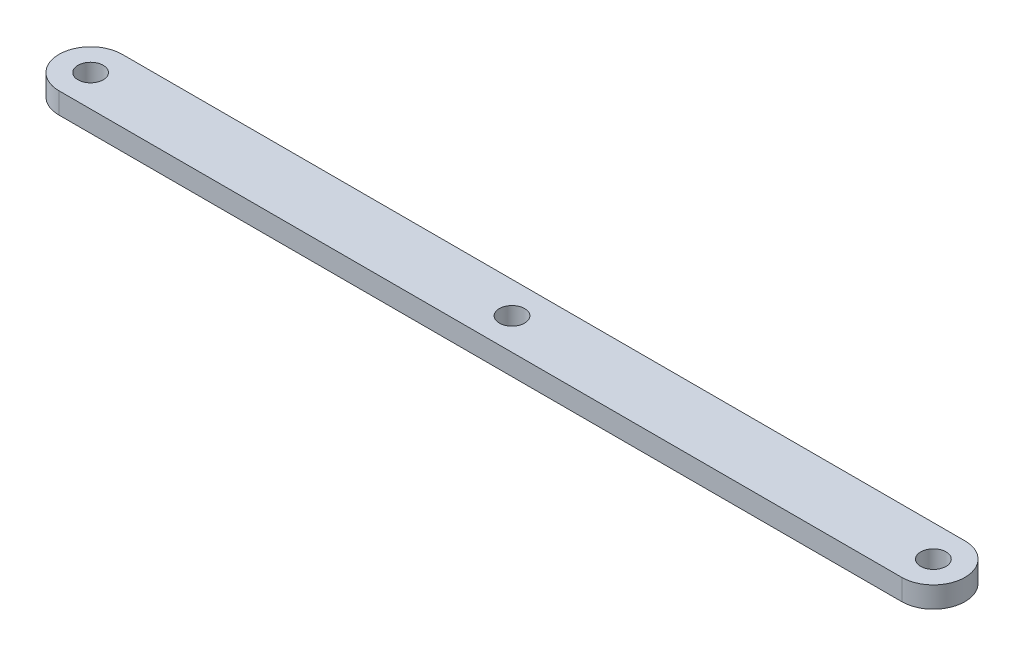
from build123d import *

# Parameters (mm, degrees)
SKETCH1_R           = 3
BOSS_EXTRUDE1_DEPTH = 5


with BuildPart() as part:
    # Sketch1 → Boss-Extrude1 (new body)
    with BuildSketch(Plane(origin=(0, 0, 0), x_dir=(1, 0, 0), z_dir=(0, 1, 0))):
        with BuildLine():
            Line((0, 7.5), (200, 7.5))
            ThreePointArc((200, 7.5), (207.5, 0), (200, -7.5))
            Line((200, -7.5), (0, -7.5))
            ThreePointArc((0, -7.5), (-7.5, 0), (0, 7.5))
        make_face()
        with Locations((200, 0)):
            Circle(SKETCH1_R, mode=Mode.SUBTRACT)
        Circle(SKETCH1_R, mode=Mode.SUBTRACT)
        with Locations((100, 0)):
            Circle(SKETCH1_R, mode=Mode.SUBTRACT)
    extrude(amount=BOSS_EXTRUDE1_DEPTH)


solid = part.part
